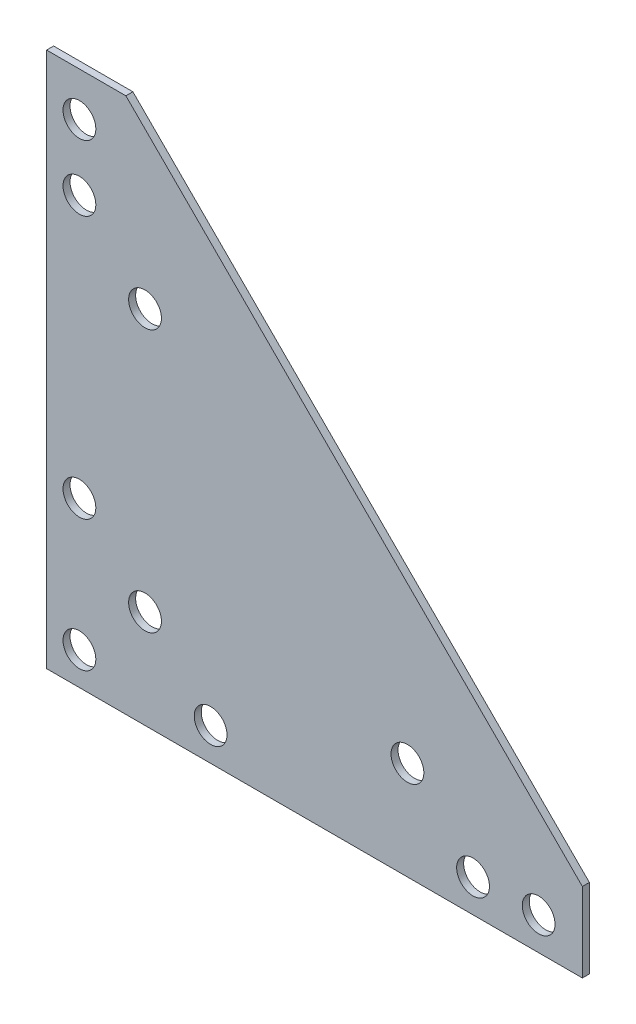
from build123d import *

# Parameters (mm, degrees)
BOSS_EXTRUDE1_DEPTH      = 1.016
BOSS_EXTRUDE1_DEPTH_BACK = 1.016
SKETCH5_R                = 4.7625
CUT_EXTRUDE1_DEPTH       = 2.016
CUT_EXTRUDE1_DEPTH_BACK  = 2.016


with BuildPart() as part:
    # Sketch4 → Boss-Extrude1 (new body, two sides)
    with BuildSketch(Plane.XY) as boss_extrude1_sk:
        Polygon((-54.76875, 77.7875), (-77.7875, 77.7875), (-77.7875, -77.7875), (77.7875, -77.7875), (77.7875, -54.76875), align=None)
    extrude(amount=BOSS_EXTRUDE1_DEPTH)
    extrude(boss_extrude1_sk.sketch, amount=-BOSS_EXTRUDE1_DEPTH_BACK)

    # Sketch5 → Cut-Extrude1 (cut, two sides)
    with BuildSketch(Plane.XY) as cut_extrude1_sk:
        with Locations((-68.2625, 65.0875)):
            Circle(SKETCH5_R)
        with Locations((-68.2625, 46.0375)):
            Circle(SKETCH5_R)
        with Locations((-68.2625, -30.1625)):
            Circle(SKETCH5_R)
        with Locations((-49.2125, 26.9875)):
            Circle(SKETCH5_R)
        with Locations((-49.2125, -49.2125)):
            Circle(SKETCH5_R)
        with Locations((-68.2625, -68.2625)):
            Circle(SKETCH5_R)
        with Locations((-30.1625, -68.2625)):
            Circle(SKETCH5_R)
        with Locations((46.0375, -68.2625)):
            Circle(SKETCH5_R)
        with Locations((26.9875, -49.2125)):
            Circle(SKETCH5_R)
        with Locations((65.0875, -68.2625)):
            Circle(SKETCH5_R)
    extrude(amount=CUT_EXTRUDE1_DEPTH, mode=Mode.SUBTRACT)
    extrude(cut_extrude1_sk.sketch, amount=-CUT_EXTRUDE1_DEPTH_BACK, mode=Mode.SUBTRACT)


solid = part.part
